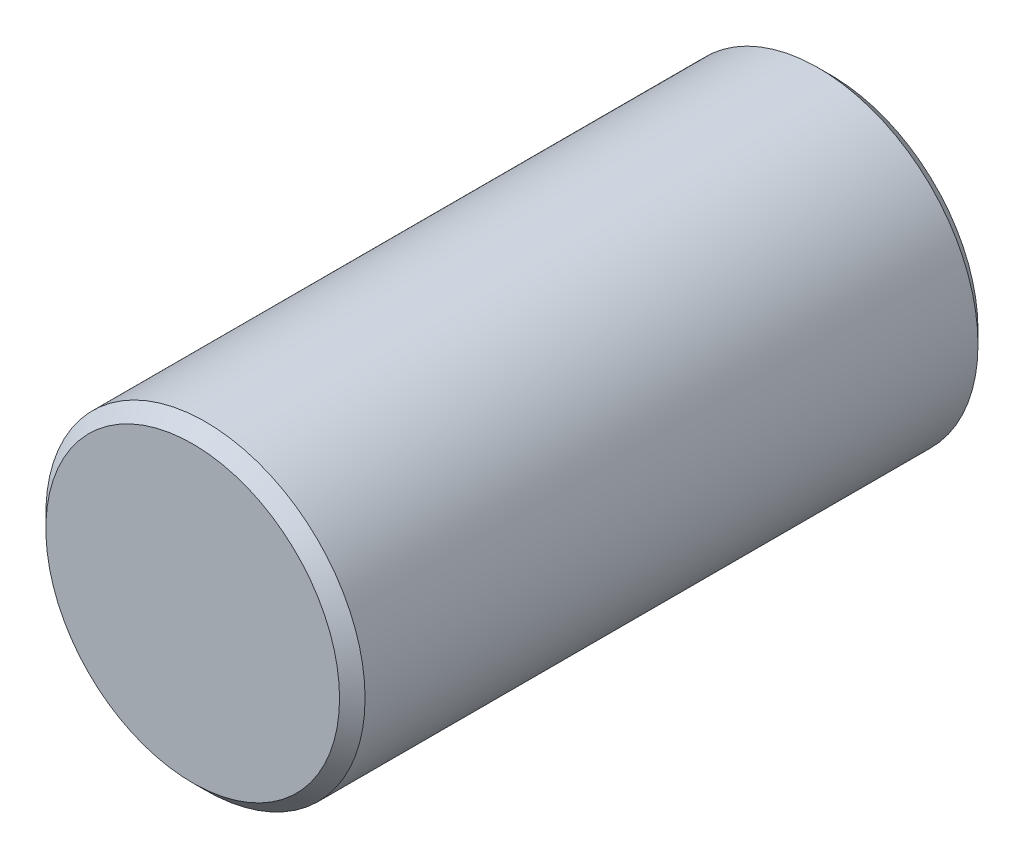
from build123d import *

# Parameters (mm, degrees)
SKETCH1_R           = 1.25
BOSS_EXTRUDE1_DEPTH = 5
CHAMFER1_SIZE       = 0.1


with BuildPart() as part:
    # Sketch1 → Boss-Extrude1 (new body)
    with BuildSketch(Plane.XY):
        Circle(SKETCH1_R)
    extrude(amount=BOSS_EXTRUDE1_DEPTH)

    # Chamfer1
    chamfer1_edges = [part.edges().sort_by_distance(p)[0] for p in [
        (-1.25, 0, 0),
        (-1.25, 0, 5),
    ]]
    chamfer(chamfer1_edges, length=CHAMFER1_SIZE)


solid = part.part
